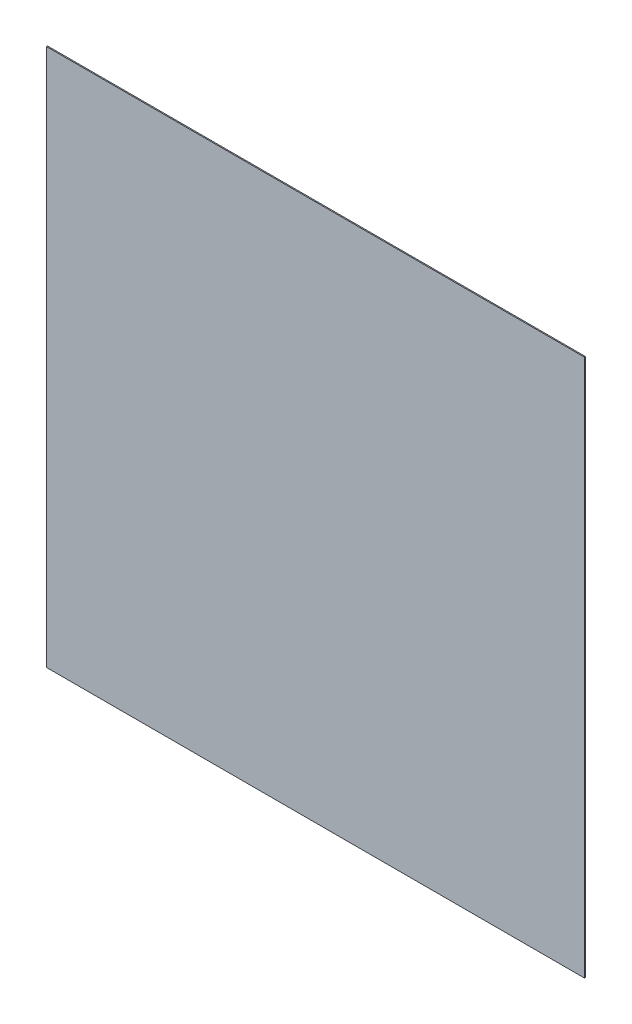
from build123d import *

# Parameters (mm, degrees)
SKETCH_1_W      = 5000
SKETCH_1_H      = 5000
EXTRUDE_1_DEPTH = 10


with BuildPart() as part:
    # 草图1 → 凸台-拉伸1 (new body)
    with BuildSketch(Plane.XY):
        with Locations((2425.637216468, -2458.590623886)):
            Rectangle(SKETCH_1_W, SKETCH_1_H)
    extrude(amount=EXTRUDE_1_DEPTH)


solid = part.part
